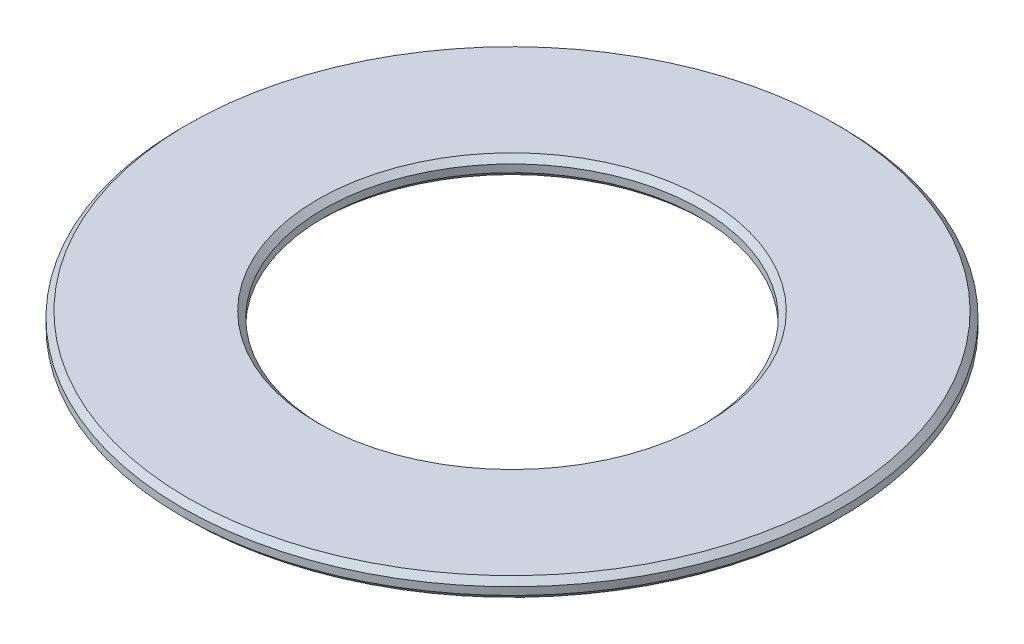
from build123d import *

# Parameters (mm, degrees)
SKETCH1_R           = 17.5
SKETCH1_R_2         = 10
BOSS_EXTRUDE1_DEPTH = 0.5
CHAMFER1_SIZE       = 0.3


with BuildPart() as part:
    # Sketch1 → Boss-Extrude1 (new body, symmetric)
    with BuildSketch(Plane(origin=(0, 0, 0), x_dir=(1, 0, 0), z_dir=(0, 1, 0))):
        Circle(SKETCH1_R)
        Circle(SKETCH1_R_2, mode=Mode.SUBTRACT)
    extrude(amount=BOSS_EXTRUDE1_DEPTH, both=True)

    # Chamfer1
    chamfer1_edges = [part.edges().sort_by_distance(p)[0] for p in [
        (-17.5, -0.5, 0),
        (-17.5, 0.5, 0),
        (-10, -0.5, 0),
        (-10, 0.5, 0),
    ]]
    chamfer(chamfer1_edges, length=CHAMFER1_SIZE)


solid = part.part
